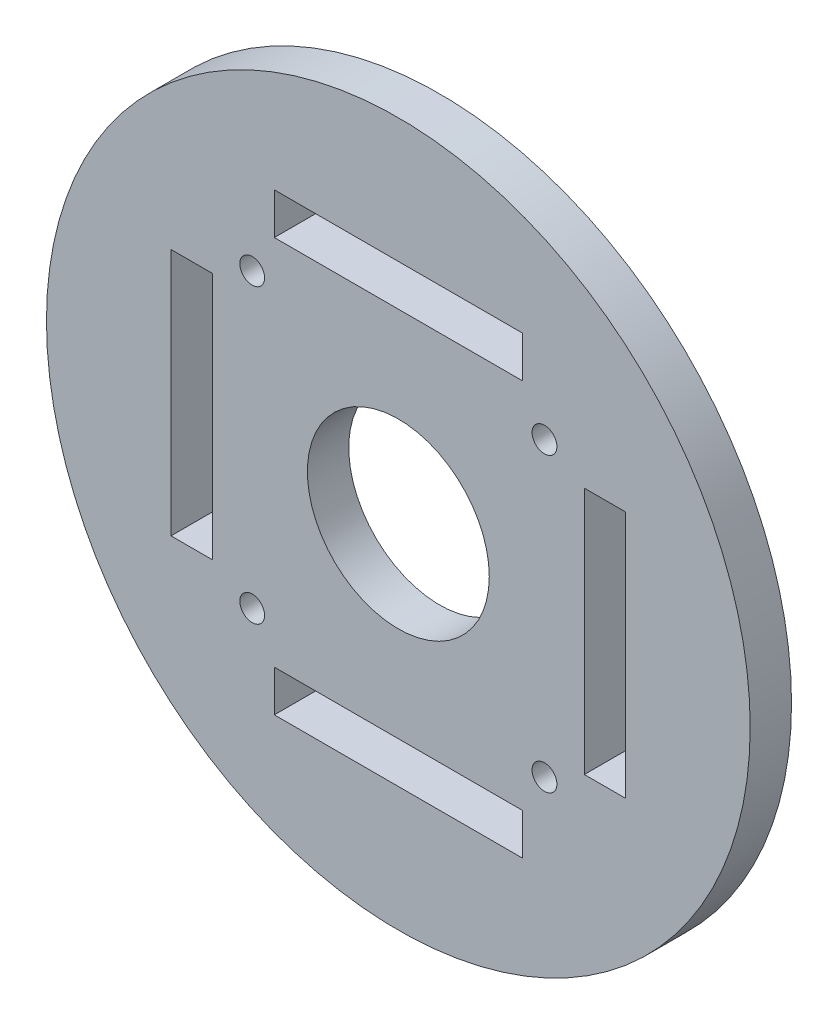
from build123d import *

# Parameters (mm, degrees)
SCHIZZO1_R                   = 42.562660939
ESTRUSIONE_ESTRUSIONE1_DEPTH = 5
SCHIZZO3_R                   = 11
TAGLIO_ESTRUSIONE2_DEPTH     = 6
SCHIZZO4_R                   = 1.5
SCHIZZO4_W                   = 5
SCHIZZO4_H                   = 30
SCHIZZO4_W_2                 = 30
SCHIZZO4_H_2                 = 5
TAGLIO_ESTRUSIONE3_DEPTH     = 6


with BuildPart() as part:
    # Schizzo1 → Estrusione-Estrusione1 (new body)
    with BuildSketch(Plane.XY):
        Circle(SCHIZZO1_R)
    extrude(amount=ESTRUSIONE_ESTRUSIONE1_DEPTH)

    # Schizzo3 → Taglio-Estrusione2 (cut, through all)
    with BuildSketch(Plane.XY):
        Circle(SCHIZZO3_R)
    extrude(amount=TAGLIO_ESTRUSIONE2_DEPTH, mode=Mode.SUBTRACT)

    # Schizzo4 → Taglio-Estrusione3 (cut, through all)
    with BuildSketch(Plane.XY):
        with Locations((17.67766953, 17.67766953)):
            Circle(SCHIZZO4_R)
        with Locations((17.67766953, -17.67766953)):
            Circle(SCHIZZO4_R)
        with Locations((-17.67766953, -17.67766953)):
            Circle(SCHIZZO4_R)
        with Locations((-17.67766953, 17.67766953)):
            Circle(SCHIZZO4_R)
        with Locations((-25, 0)):
            Rectangle(SCHIZZO4_W, SCHIZZO4_H)
        with Locations((0, 25)):
            Rectangle(SCHIZZO4_W_2, SCHIZZO4_H_2)
        with Locations((25, 0)):
            Rectangle(SCHIZZO4_W, SCHIZZO4_H)
        with Locations((0, -25)):
            Rectangle(SCHIZZO4_W_2, SCHIZZO4_H_2)
    extrude(amount=TAGLIO_ESTRUSIONE3_DEPTH, mode=Mode.SUBTRACT)


solid = part.part
